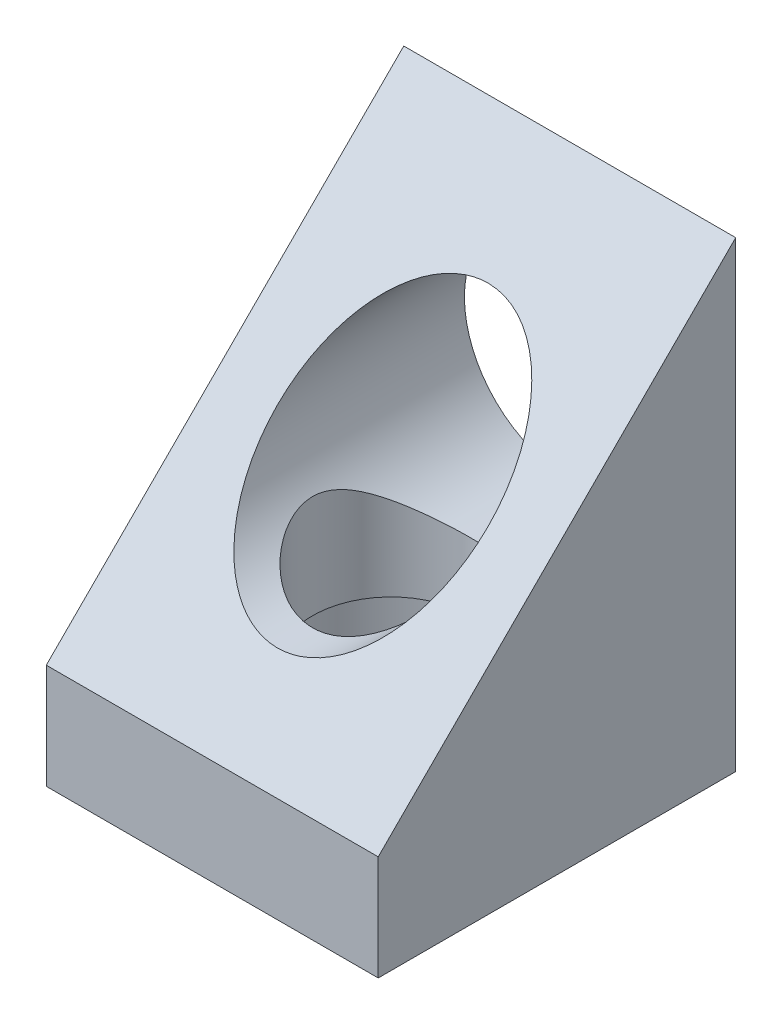
from build123d import *

# Parameters (mm, degrees)
BOSS_EXTRUDE1_DEPTH = 26
SKETCH2_R           = 8.25
CUT_EXTRUDE1_DEPTH  = 29
SKETCH3_R           = 6.15
CUT_EXTRUDE2_DEPTH  = 37.22
SKETCH4_R           = 10.325
SKETCH4_R_2         = 1.25
CUT_EXTRUDE3_DEPTH  = 8


with BuildPart() as part:
    # Sketch1 → Boss-Extrude1 (new body)
    with BuildSketch(Plane(origin=(0, 0, 0), x_dir=(0, 0, -1), z_dir=(1, 0, 0))):
        Polygon((0, 0), (28, 0), (28, 36.22), (0, 8.22), align=None)
    extrude(amount=BOSS_EXTRUDE1_DEPTH)

    # Sketch2 → Cut-Extrude1 (cut, through all)
    with BuildSketch(Plane(origin=(0, 0, -28), x_dir=(-1, 0, 0), z_dir=(0, 0, -1))):
        with Locations((-13, 21.58)):
            Circle(SKETCH2_R)
    extrude(amount=-CUT_EXTRUDE1_DEPTH, mode=Mode.SUBTRACT)

    # Sketch3 → Cut-Extrude2 (cut, through all)
    with BuildSketch(Plane.XZ):
        with Locations((13, -14)):
            Circle(SKETCH3_R)
    extrude(amount=-CUT_EXTRUDE2_DEPTH, mode=Mode.SUBTRACT)

    # Sketch4 → Cut-Extrude3 (cut)
    with BuildSketch(Plane.XZ):
        with Locations((13, -14)):
            Circle(SKETCH4_R)
        with Locations((3.9, -3.85)):
            Circle(SKETCH4_R_2)
        with Locations((23.05, -3.75)):
            Circle(SKETCH4_R_2)
        with Locations((22.85, -22.95)):
            Circle(SKETCH4_R_2)
        with Locations((3.7, -22.65)):
            Circle(SKETCH4_R_2)
    extrude(amount=-CUT_EXTRUDE3_DEPTH, mode=Mode.SUBTRACT)


solid = part.part
